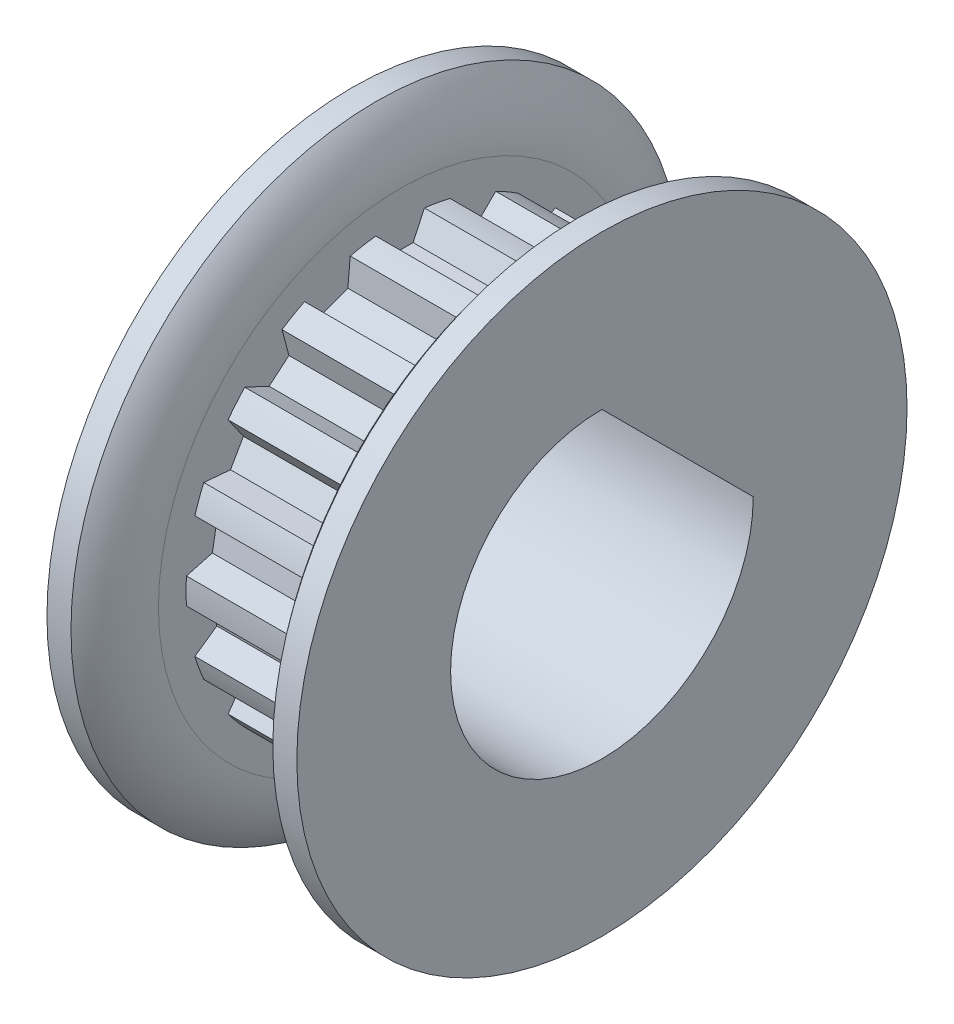
from build123d import *

# Parameters (mm, degrees)
SKETCH4_R          = 5.8166
SKETCH4_R_2        = 5.65785
CUT_EXTRUDE2_DEPTH = 4.064
CUT_EXTRUDE1_DEPTH = 4.064
CIRPATTERN1_COUNT  = 18
SKETCH6_R          = 1.4605
CUT_EXTRUDE3_DEPTH = 13.95590486
CIRPATTERN2_COUNT  = 2
CIRPATTERN2_ANGLE  = 90
CUT_EXTRUDE5_REACH = 15.179
SKETCH9_R          = 8.0645
CUT_EXTRUDE6_REACH = 15.179
SKETCH10_R         = 2.38125


with BuildPart() as part:
    # Sketch1 → Revolve1 (revolve)
    with BuildSketch(Plane.XY, mode=Mode.PRIVATE) as revolve1_sk:
        with BuildLine():
            Line((-6.1468, 2.38125), (6.1468, 2.38125))
            Line((6.1468, 2.38125), (6.1468, 8.0645))
            Line((6.1468, 8.0645), (5.5118, 8.0645))
            ThreePointArc((5.5118, 8.0645), (5.040869168, 7.284417739), (4.8768, 6.3881))
            Line((4.8768, 6.3881), (4.8768, 5.8166))
            Line((4.8768, 5.8166), (0.8128, 5.8166))
            Line((0.8128, 5.8166), (0.8128, 6.3881))
            ThreePointArc((0.8128, 6.3881), (0.648730832, 7.284417739), (0.1778, 8.0645))
            Line((0.1778, 8.0645), (-0.4572, 8.0645))
            Line((-0.4572, 8.0645), (-0.4572, 3.9624))
            Line((-0.4572, 3.9624), (-6.1468, 3.9624))
            Line((-6.1468, 3.9624), (-6.1468, 2.38125))
        make_face()
    revolve(revolve1_sk.sketch.rotate(Axis((-6.1468, 0, 0), (1, 0, 0)), 90), axis=Axis((-6.1468, 0, 0), (1, 0, 0)))

    # Sketch4 → Cut-Extrude2 (cut)
    with BuildSketch(Plane(origin=(0.8128, 0, 0), x_dir=(0, 0, -1), z_dir=(1, 0, 0))):
        Circle(SKETCH4_R)
        Circle(SKETCH4_R_2, mode=Mode.SUBTRACT)
    extrude(amount=CUT_EXTRUDE2_DEPTH, mode=Mode.SUBTRACT)

    # Sketch3 → Cut-Extrude1 (cut)
    with BuildSketch(Plane(origin=(0.8128, 0, 0), x_dir=(0, 0, -1), z_dir=(1, 0, 0))):
        with BuildLine():
            Line((-0.64235315, 5.621267566), (-0.342998874, 4.97930025))
            Line((-0.342998874, 4.97930025), (0.342998874, 4.97930025))
            Line((0.342998874, 4.97930025), (0.64235315, 5.621267566))
            ThreePointArc((0.64235315, 5.621267566), (0, 5.65785), (-0.64235315, 5.621267566))
        make_face()
    cut_extrude1 = extrude(amount=CUT_EXTRUDE1_DEPTH, mode=Mode.SUBTRACT)

    # CirPattern1: Cut-Extrude1 ×18 about axis
    cirpattern1_axis = Axis((0, 0, 0), (1, 0, 0))
    for i in range(1, CIRPATTERN1_COUNT):
        add(cut_extrude1.rotate(cirpattern1_axis, i * 360 / CIRPATTERN1_COUNT), mode=Mode.SUBTRACT)

    # Sketch6 → Cut-Extrude3 (cut, through all)
    with BuildSketch(Plane(origin=(0, 0, 0), x_dir=(1, 0, 0), z_dir=(0, 1, 0))):
        with Locations(Location((-3.302, 0, 0), (0, 0, 90))):
            Circle(SKETCH6_R)
    cut_extrude3 = extrude(amount=CUT_EXTRUDE3_DEPTH, mode=Mode.SUBTRACT)

    # CirPattern2: Cut-Extrude3 ×2 about axis
    cirpattern2_axis = Axis((-6.1468, 0, 0), (1, 0, 0))
    for i in range(1, CIRPATTERN2_COUNT):
        add(cut_extrude3.rotate(cirpattern2_axis, i * CIRPATTERN2_ANGLE / (CIRPATTERN2_COUNT - 1)), mode=Mode.SUBTRACT)

    # Sketch9 → Cut-Extrude5 (cut, up to next)
    with BuildSketch(Plane.ZY.offset(0.4572), mode=Mode.PRIVATE) as cut_extrude5_sk1:
        Circle(SKETCH9_R)
    cut_extrude5_tool1 = extrude(cut_extrude5_sk1.sketch, amount=CUT_EXTRUDE5_REACH, mode=Mode.PRIVATE) & part.part
    add(cut_extrude5_tool1.solids().sort_by_distance((-0.4572, 0, 0))[0], mode=Mode.SUBTRACT)

    # Sketch10 → Cut-Extrude6 (cut, up to next)
    with BuildSketch(Plane(origin=(6.1468, 0, 0), x_dir=(0, 0, -1), z_dir=(1, 0, 0)), mode=Mode.PRIVATE) as cut_extrude6_sk1:
        with BuildLine():
            Line((4, 0), (0, 4))
            ThreePointArc((0, 4), (-2.828427125, -2.828427125), (4, 0))
        make_face()
        Circle(SKETCH10_R, mode=Mode.SUBTRACT)
    cut_extrude6_tool1 = extrude(cut_extrude6_sk1.sketch, amount=-CUT_EXTRUDE6_REACH, mode=Mode.PRIVATE) & part.part
    add(cut_extrude6_tool1.solids().sort_by_distance((6.1468, 1.92, -1.92))[0], mode=Mode.SUBTRACT)


solid = part.part
